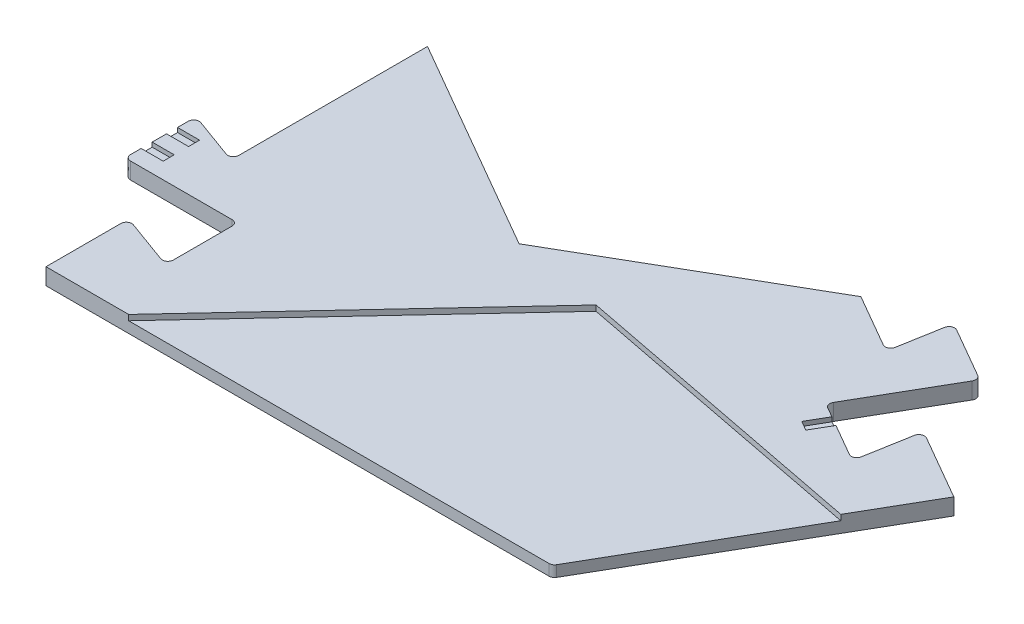
from build123d import *

# Parameters (mm, degrees)
P_IDAT_VYSUNUT_M1_DEPTH  = 3
P_IDAT_VYSUNUT_M2_DEPTH  = 2
ZAOBLIT1_R               = 1
ZAOBLIT2_R               = 1
SKICA2_W                 = 4
SKICA2_H                 = 2
ODEBRAT_VYSUNUT_M1_DEPTH = 0.8


with BuildPart() as part:
    # Skica1 → P_idat vysunut_m1 (new body)
    with BuildSketch(Plane(origin=(0, 0, 0), x_dir=(1, 0, 0), z_dir=(0, 1, 0))):
        Polygon((118.524103266, 46.190077074), (105.53372221, 53.690077074), (103.593400635, 42.685966604), (92.248467845, 49.235966604), (102.473720104, 66.946623035), (91.301992395, 73.396623035), (89.463213481, 62.968389614), (78.635106664, 69.22), (39.317553332, 46.52), (0, 69.22), (0, 33.55662508), (-9.950504516, 37.17831254), (-9.950504516, 24.27831254), (10.5, 24.27831254), (10.5, 11.17831254), (0, 15), (0, 0), (15, 0), (55.910618513, 43.889876884), (111.018549767, 33.190077074), align=None)
    extrude(amount=P_IDAT_VYSUNUT_M1_DEPTH)

    # Skica1_3 → P_idat vysunut_m2 (add)
    with BuildSketch(Plane(origin=(0, 0, 0), x_dir=(1, 0, 0), z_dir=(0, 1, 0))):
        Polygon((91.856249834, 0), (111.018549767, 33.190077074), (55.910618513, 43.889876884), (15, 0), align=None)
    extrude(amount=P_IDAT_VYSUNUT_M2_DEPTH)

    # Zaoblit1
    zaoblit1_edges = [part.edges().sort_by_distance(p)[0] for p in [
        (0, 1.5, -33.55662508),
        (-9.950504516, 1.5, -37.17831254),
        (10.5, 1.5, -24.27831254),
        (-9.950504516, 1.5, -24.27831254),
        (10.5, 1.5, -11.17831254),
        (0, 1.5, -15),
        (105.53372221, 1.5, -53.690077074),
        (103.593400635, 1.5, -42.685966604),
        (92.248467845, 1.5, -49.235966604),
        (89.463213481, 1.5, -62.968389614),
        (91.301992395, 1.5, -73.396623035),
        (102.473720104, 1.5, -66.946623035),
    ]]
    fillet(zaoblit1_edges, radius=ZAOBLIT1_R)

    # Zaoblit2
    zaoblit2_edges = [part.edges().sort_by_distance(p)[0] for p in [
        (91.856249834, 1, 0),
    ]]
    fillet(zaoblit2_edges, radius=ZAOBLIT2_R)

    # Skica2 → Odebrat vysunut_m1 (cut)
    with BuildSketch(Plane(origin=(0, 3, 0), x_dir=(1, 0, 0), z_dir=(0, 1, 0))):
        with Locations((-7.950504516, 32.814238537)):
            Rectangle(SKICA2_W, SKICA2_H)
        with Locations((-7.950504516, 28.214238537)):
            Rectangle(SKICA2_W, SKICA2_H)
        Polygon((94.877656883, 47.718003606), (96.60970769, 46.718003606), (94.60970769, 43.253901991), (92.877656883, 44.253901991), align=None)
    extrude(amount=-ODEBRAT_VYSUNUT_M1_DEPTH, mode=Mode.SUBTRACT)


solid = part.part
